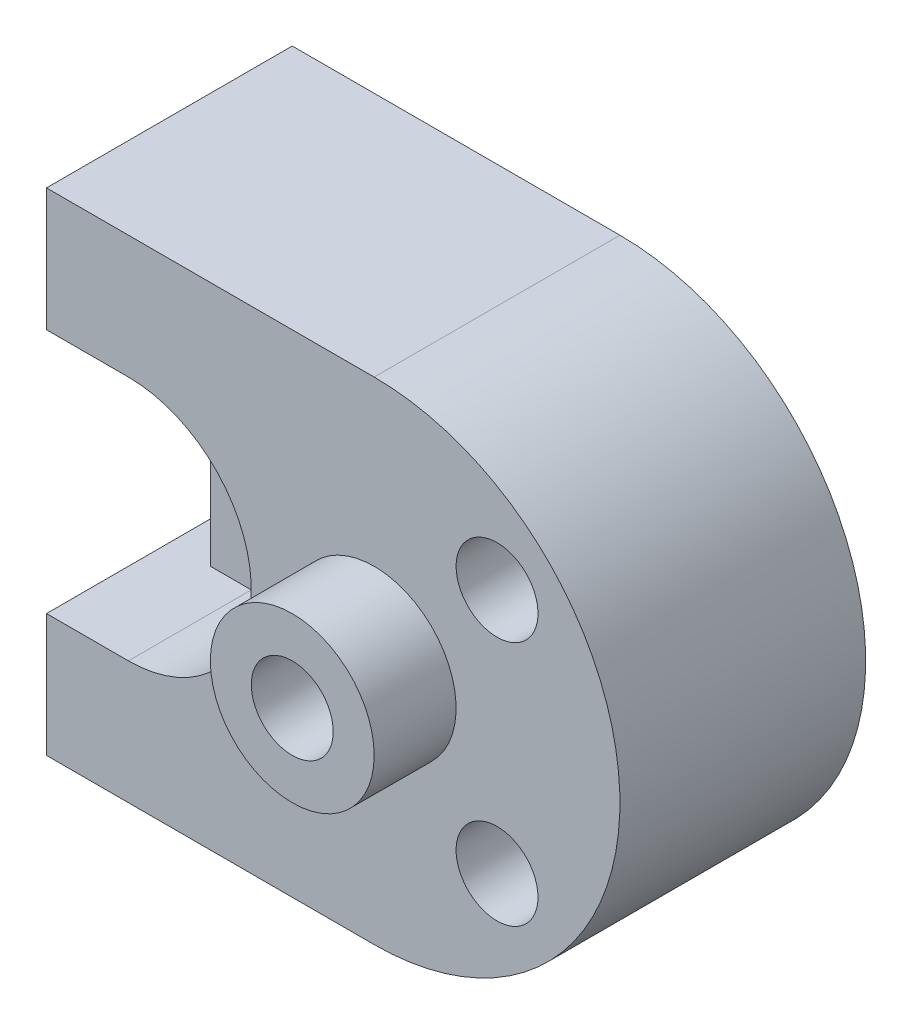
from build123d import *

# Parameters (mm, degrees)
SKETCH1_W                  = 140
SKETCH1_H                  = 120
BOSS_EXTRUDE1_DEPTH        = 60
SKETCH2_W                  = 10
SKETCH2_H                  = 60
CUT_EXTRUDE1_DEPTH         = 60
CUT_EXTRUDE2_DEPTH         = 60
SKETCH4_R                  = 10
CUT_EXTRUDE3_DEPTH         = 60
SKETCH5_R                  = 10
CUT_EXTRUDE4_DEPTH         = 60
SKETCH6_R                  = 10
CUT_EXTRUDE5_DEPTH         = 60
SKETCH7_R                  = 5
CUT_EXTRUDE6_DEPTH         = 60
SKETCH8_R                  = 10
CUT_EXTRUDE7_DEPTH         = 20
SKETCH9_R                  = 5
CUT_EXTRUDE8_DEPTH         = 47
SKETCH10_R                 = 10
CUT_EXTRUDE9_DEPTH         = 20
SKETCH11_R                 = 20
BOSS_EXTRUDE2_DEPTH        = 20
F_20_0MM_DOWEL_HOLE1_D     = 20
F_20_0MM_DOWEL_HOLE1_DEPTH = 30
F_20_0MM_DOWEL_HOLE1_TIP   = 6.00860619


with BuildPart() as part:
    # Sketch1 → Boss-Extrude1 (new body)
    with BuildSketch(Plane.XY):
        with Locations((70, 60)):
            Rectangle(SKETCH1_W, SKETCH1_H)
    extrude(amount=BOSS_EXTRUDE1_DEPTH)

    # Sketch2 → Cut-Extrude1 (cut)
    with BuildSketch(Plane.XY.offset(60)):
        with BuildLine():
            Line((140, 120), (80, 120))
            ThreePointArc((80, 120), (122.426406871, 102.426406871), (140, 60))
            Line((140, 60), (140, 120))
        make_face()
        with BuildLine():
            Line((140, 0), (140, 60))
            ThreePointArc((140, 60), (122.426406871, 17.573593129), (80, 0))
            Line((80, 0), (140, 0))
        make_face()
        with Locations((5, 60)):
            Rectangle(SKETCH2_W, SKETCH2_H)
    extrude(amount=-CUT_EXTRUDE1_DEPTH, mode=Mode.SUBTRACT)

    # Sketch3 → Cut-Extrude2 (cut)
    with BuildSketch(Plane.XY.offset(30)):
        with BuildLine():
            ThreePointArc((20, 90), (50, 60), (20, 30))
            Line((20, 30), (10, 30))
            Line((10, 30), (10, 90))
            Line((10, 90), (20, 90))
        make_face()
    extrude(amount=CUT_EXTRUDE2_DEPTH, mode=Mode.SUBTRACT)

    # Sketch4 → Cut-Extrude3 (cut)
    with BuildSketch(Plane.XY.offset(30)):
        with Locations((30, 60)):
            Circle(SKETCH4_R)
    extrude(amount=-CUT_EXTRUDE3_DEPTH, mode=Mode.SUBTRACT)

    # Sketch5 → Cut-Extrude4 (cut)
    with BuildSketch(Plane.XY.offset(20)):
        with Locations((110, 90)):
            Circle(SKETCH5_R)
    extrude(amount=-CUT_EXTRUDE4_DEPTH, mode=Mode.SUBTRACT)

    # Sketch6 → Cut-Extrude5 (cut)
    with BuildSketch(Plane.XY.offset(40)):
        with Locations((110, 90)):
            Circle(SKETCH6_R)
    extrude(amount=CUT_EXTRUDE5_DEPTH, mode=Mode.SUBTRACT)

    # Sketch7 → Cut-Extrude6 (cut)
    with BuildSketch(Plane.XY.offset(40)):
        with Locations((110, 90)):
            Circle(SKETCH7_R)
    extrude(amount=-CUT_EXTRUDE6_DEPTH, mode=Mode.SUBTRACT)

    # Sketch8 → Cut-Extrude7 (cut)
    with BuildSketch(Plane.XY.offset(60)):
        with Locations((110, 30)):
            Circle(SKETCH8_R)
    extrude(amount=-CUT_EXTRUDE7_DEPTH, mode=Mode.SUBTRACT)

    # Sketch9 → Cut-Extrude8 (cut)
    with BuildSketch(Plane.XY.offset(40)):
        with Locations((110, 30)):
            Circle(SKETCH9_R)
    extrude(amount=-CUT_EXTRUDE8_DEPTH, mode=Mode.SUBTRACT)

    # Sketch10 → Cut-Extrude9 (cut)
    with BuildSketch(Plane(origin=(0, 0, 0), x_dir=(-1, 0, 0), z_dir=(0, 0, -1))):
        with Locations((-110, 30)):
            Circle(SKETCH10_R)
    extrude(amount=-CUT_EXTRUDE9_DEPTH, mode=Mode.SUBTRACT)

    # Sketch11 → Boss-Extrude2 (add)
    with BuildSketch(Plane.XY.offset(60)):
        with Locations((80, 60)):
            Circle(SKETCH11_R)
    extrude(amount=BOSS_EXTRUDE2_DEPTH)

    # Ø20.0mm Dowel Hole1
    with Locations(Plane(origin=(80, 60, 80), x_dir=(1, 0, 0), z_dir=(0, 0, 1))):
        with Locations((0, 0)):
            Hole(F_20_0MM_DOWEL_HOLE1_D / 2, depth=F_20_0MM_DOWEL_HOLE1_DEPTH)
            with Locations((0, 0, -(F_20_0MM_DOWEL_HOLE1_DEPTH + F_20_0MM_DOWEL_HOLE1_TIP / 2))):  # 118° drill point
                Cone(0, F_20_0MM_DOWEL_HOLE1_D / 2, F_20_0MM_DOWEL_HOLE1_TIP, mode=Mode.SUBTRACT)


solid = part.part
